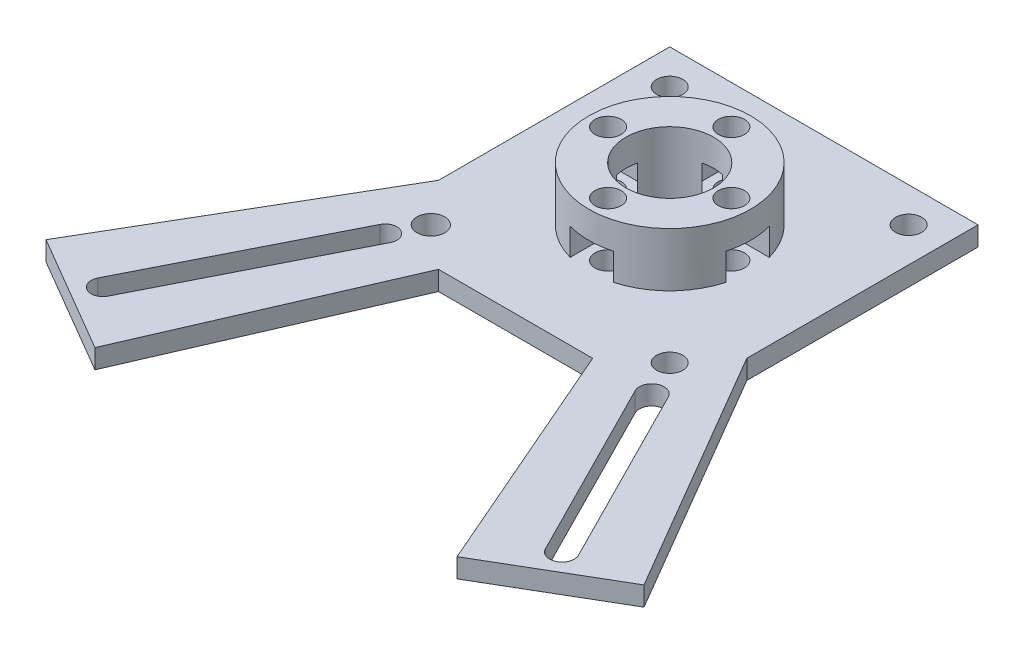
from build123d import *

# Parameters (mm, degrees)
SKETCH_1_R          = 1.7
SKETCH_1_R_2        = 1.8
SKETCH_1_R_3        = 5.7
EXTRUDE_1_DEPTH     = 2.5
SKETCH_2_R          = 10.5
EXTRUDE_2_DEPTH     = 7
SKETCH_4_R          = 1.7
CUT_EXTRUDE_1_DEPTH = 7
CUT_EXTRUDE_2_DEPTH = 3.5
SKETCH_6_R          = 5.7
CUT_EXTRUDE_3_DEPTH = 20


with BuildPart() as part:
    # 草图1 → 凸台-拉伸1 (new body)
    with BuildSketch(Plane(origin=(0, 0, 0), x_dir=(1, 0, 0), z_dir=(0, 1, 0))):
        Polygon((-9.99944515, -20.000324527), (10.00055485, -20.000324527), (23.493176713, -51.085714784), (38.795982487, -42.134997854), (20, -10), (20, 20), (-20, 20), (-20, -10), (-38.79573581, -42.1354119), (-23.493239928, -51.085714784), align=None)
        with Locations((15.5, 15.5)):
            Circle(SKETCH_1_R, mode=Mode.SUBTRACT)
        with Locations((-15.5, -15.5)):
            Circle(SKETCH_1_R_2, mode=Mode.SUBTRACT)
        with Locations((-15.5, 15.5)):
            Circle(SKETCH_1_R, mode=Mode.SUBTRACT)
        Circle(SKETCH_1_R_3, mode=Mode.SUBTRACT)
        with Locations((-8, 0)):
            Circle(SKETCH_1_R, mode=Mode.SUBTRACT)
        with Locations((0, 8)):
            Circle(SKETCH_1_R, mode=Mode.SUBTRACT)
        with Locations((8, 0)):
            Circle(SKETCH_1_R, mode=Mode.SUBTRACT)
        with Locations((0, -8)):
            Circle(SKETCH_1_R, mode=Mode.SUBTRACT)
        with Locations((15.5, -15.5)):
            Circle(SKETCH_1_R, mode=Mode.SUBTRACT)
        with BuildLine():
            Line((-16.131862345, -20.121977189), (-28.419219954, -44.445930008))
            ThreePointArc((-28.419219954, -44.445930008), (-30.461319047, -45.117305053), (-31.132694091, -43.07520596))
            Line((-31.132694091, -43.07520596), (-18.845336482, -18.75125314))
            ThreePointArc((-18.845336482, -18.75125314), (-16.803237389, -18.079878096), (-16.131862345, -20.121977189))
        make_face(mode=Mode.SUBTRACT)
        with BuildLine():
            Line((19.251434516, -19.436615165), (31.203359651, -43.037711333))
            ThreePointArc((31.203359651, -43.037711333), (30.498813674, -45.187970612), (28.348554395, -44.483424635))
            Line((28.348554395, -44.483424635), (16.39662926, -20.882328467))
            ThreePointArc((16.39662926, -20.882328467), (17.101175237, -18.732069188), (19.251434516, -19.436615165))
        make_face(mode=Mode.SUBTRACT)
    extrude(amount=EXTRUDE_1_DEPTH)

    # 草图2 → 凸台-拉伸2 (add)
    with BuildSketch(Plane(origin=(0, 2.5, 0), x_dir=(1, 0, 0), z_dir=(0, 1, 0))):
        Circle(SKETCH_2_R)
    extrude(amount=EXTRUDE_2_DEPTH)

    # 草图4 → 切除-拉伸1 (cut)
    with BuildSketch(Plane.XZ.offset(-2.5)):
        with Locations((0, -8)):
            Circle(SKETCH_4_R)
        with Locations((-8, 0)):
            Circle(SKETCH_4_R)
        with Locations((8, 0)):
            Circle(SKETCH_4_R)
        with Locations((0, 8)):
            Circle(SKETCH_4_R)
    extrude(amount=-CUT_EXTRUDE_1_DEPTH, mode=Mode.SUBTRACT)

    # 草图5 → 切除-拉伸2 (cut)
    with BuildSketch(Plane(origin=(0, 2.5, 0), x_dir=(1, 0, 0), z_dir=(0, 1, 0))):
        Polygon((-4.766838493, 0), (-6.383419246, 2.8), (-11.233161507, 2.8), (-11.233161507, -2.8), (-6.383419246, -2.8), align=None)
        Polygon((4.766838493, 0), (6.383419246, -2.8), (11.233161507, -2.8), (11.233161507, 2.8), (6.383419246, 2.8), align=None)
        Polygon((-2.8, 11.233161507), (-2.8, 6.383419246), (0, 4.766838493), (2.8, 6.383419246), (2.8, 11.233161507), align=None)
        Polygon((0, -4.766838493), (-2.8, -6.383419246), (-2.8, -11.233161507), (2.8, -11.233161507), (2.8, -6.383419246), align=None)
    extrude(amount=CUT_EXTRUDE_2_DEPTH, mode=Mode.SUBTRACT)

    # 草图6 → 切除-拉伸3 (cut)
    with BuildSketch(Plane.XZ.offset(-2.5)):
        Circle(SKETCH_6_R)
    extrude(amount=-CUT_EXTRUDE_3_DEPTH, mode=Mode.SUBTRACT)


solid = part.part
